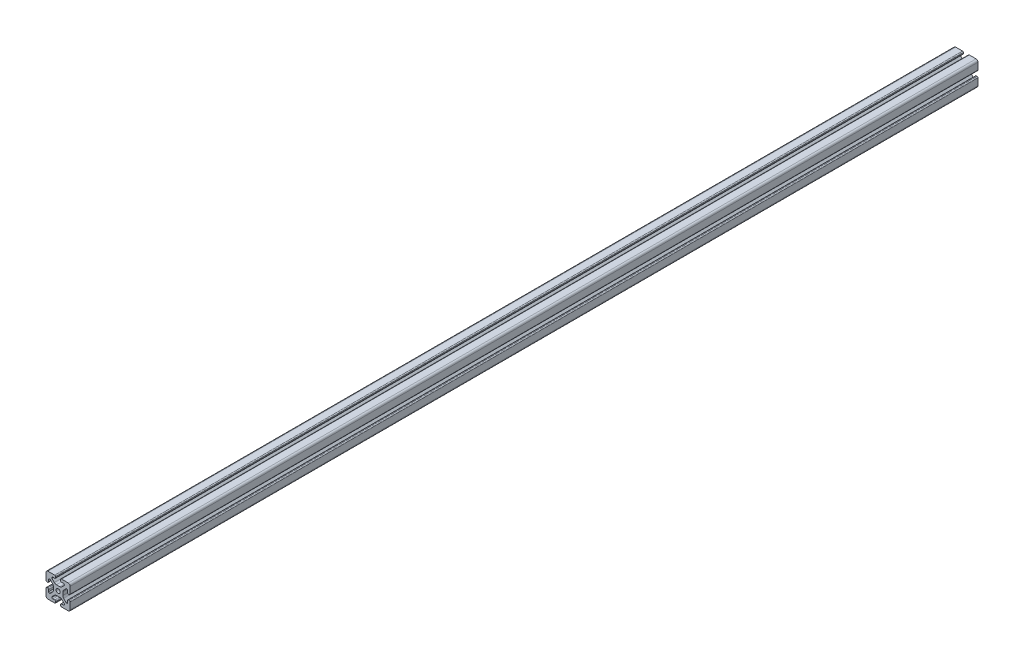
from build123d import *

# Parameters (mm, degrees)
SKETCH1_R           = 3.4
BOSS_EXTRUDE1_DEPTH = 1500


with BuildPart() as part:
    # Sketch1 → Boss-Extrude1 (new body)
    with BuildSketch(Plane.XY):
        with BuildLine():
            Line((-8.715, -15.524615034), (-5.63, -15.524615034))
            ThreePointArc((-5.63, -15.524615034), (-4.519842354, -15.984457388), (-4.06, -17.094615034))
            Line((-4.06, -17.094615034), (-4.06, -18.43))
            ThreePointArc((-4.06, -18.43), (-4.519842354, -19.540157646), (-5.63, -20))
            Line((-5.63, -20), (-16.674615034, -20))
            ThreePointArc((-16.674615034, -20), (-18.951578385, -19.194274381), (-20, -17.018368134))
            Line((-20, -17.018368134), (-20, -5.757918808))
            ThreePointArc((-20, -5.757918808), (-19.564709668, -4.603883664), (-18.43, -4.120449326))
            Line((-18.43, -4.120449326), (-17.248545805, -4.120449326))
            ThreePointArc((-17.248545805, -4.120449326), (-16.114784845, -4.604407881), (-15.67999625, -5.757919334))
            Line((-15.67999625, -5.757919334), (-15.67999625, -8.715399492))
            ThreePointArc((-15.67999625, -8.715399492), (-15.220153896, -9.825557139), (-14.10999625, -10.285399492))
            Line((-14.10999625, -10.285399492), (-13.816903094, -10.285399492))
            ThreePointArc((-13.816903094, -10.285399492), (-13.526063686, -10.227547937), (-13.279501941, -10.062800646))
            Line((-13.279501941, -10.062800646), (-9.076242789, -5.859541495))
            ThreePointArc((-9.076242789, -5.859541495), (-8.046572221, -4.318530588), (-7.685, -2.500784284))
            Line((-7.685, -2.500784284), (-7.685, 2.500784284))
            ThreePointArc((-7.685, 2.500784284), (-8.046572221, 4.318530588), (-9.076242789, 5.859541495))
            Line((-9.076242789, 5.859541495), (-13.040489136, 9.823787841))
            ThreePointArc((-13.040489136, 9.823787841), (-13.354224618, 10.012729352), (-13.71989919, 10.033001362))
            Line((-13.71989919, 10.033001362), (-14.05520779, 10.044710596))
            ThreePointArc((-14.05520779, 10.044710596), (-15.200613642, 9.605030484), (-15.68, 8.475666998))
            Line((-15.68, 8.475666998), (-15.68, 5.572979049))
            ThreePointArc((-15.68, 5.572979049), (-16.139842354, 4.462821403), (-17.25, 4.002979049))
            Line((-17.25, 4.002979049), (-18.43, 4.002979049))
            ThreePointArc((-18.43, 4.002979049), (-19.540157646, 4.462821403), (-20, 5.572979049))
            Line((-20, 5.572979049), (-20, 13.004526564))
            Line((-20, 13.004526564), (-20, 16.83))
            ThreePointArc((-20, 16.83), (-19.071528496, 19.071528496), (-16.83, 20))
            Line((-16.83, 20), (-5.63, 20))
            ThreePointArc((-5.63, 20), (-4.519842354, 19.540157646), (-4.06, 18.43))
            Line((-4.06, 18.43), (-4.06, 17.094615034))
            ThreePointArc((-4.06, 17.094615034), (-4.519842354, 15.984457388), (-5.63, 15.524615034))
            Line((-5.63, 15.524615034), (-8.715, 15.524615034))
            ThreePointArc((-8.715, 15.524615034), (-9.825157646, 15.06477268), (-10.285, 13.954615034))
            Line((-10.285, 13.954615034), (-10.285, 13.492503602))
            ThreePointArc((-10.285, 13.492503602), (-10.227148445, 13.201664194), (-10.062401154, 12.955102448))
            Line((-10.062401154, 12.955102448), (-6.217092793, 9.109794088))
            ThreePointArc((-6.217092793, 9.109794088), (-4.63891877, 8.055291919), (-2.777335583, 7.685))
            Line((-2.777335583, 7.685), (2.777335583, 7.685))
            ThreePointArc((2.777335583, 7.685), (4.63891877, 8.055291919), (6.217092793, 9.109794088))
            Line((6.217092793, 9.109794088), (10.062401154, 12.955102448))
            ThreePointArc((10.062401154, 12.955102448), (10.227148445, 13.201664194), (10.285, 13.492503602))
            Line((10.285, 13.492503602), (10.285, 13.954615034))
            ThreePointArc((10.285, 13.954615034), (9.825157646, 15.06477268), (8.715, 15.524615034))
            Line((8.715, 15.524615034), (5.63, 15.524615034))
            ThreePointArc((5.63, 15.524615034), (4.519842354, 15.984457388), (4.06, 17.094615034))
            Line((4.06, 17.094615034), (4.06, 18.43))
            ThreePointArc((4.06, 18.43), (4.519842354, 19.540157646), (5.63, 20))
            Line((5.63, 20), (12.979635074, 20))
            Line((12.979635074, 20), (16.83, 20))
            ThreePointArc((16.83, 20), (19.071528496, 19.071528496), (20, 16.83))
            Line((20, 16.83), (20, 13.001098436))
            Line((20, 13.001098436), (20, 5.630000526))
            ThreePointArc((20, 5.630000526), (19.540157646, 4.519842879), (18.43, 4.060000526))
            Line((18.43, 4.060000526), (17.24999625, 4.060000526))
            ThreePointArc((17.24999625, 4.060000526), (16.139838603, 4.519842879), (15.67999625, 5.630000526))
            Line((15.67999625, 5.630000526), (15.67999625, 8.715399492))
            ThreePointArc((15.67999625, 8.715399492), (15.220153896, 9.825557139), (14.10999625, 10.285399492))
            Line((14.10999625, 10.285399492), (13.816903094, 10.285399492))
            ThreePointArc((13.816903094, 10.285399492), (13.526063686, 10.227547937), (13.279501941, 10.062800646))
            Line((13.279501941, 10.062800646), (9.076242789, 5.859541495))
            ThreePointArc((9.076242789, 5.859541495), (8.046572221, 4.318530588), (7.685, 2.500784284))
            Line((7.685, 2.500784284), (7.685, -2.500784284))
            ThreePointArc((7.685, -2.500784284), (8.046572221, -4.318530588), (9.076242789, -5.859541495))
            Line((9.076242789, -5.859541495), (13.163657296, -9.946956002))
            ThreePointArc((13.163657296, -9.946956002), (13.35903797, -10.160433474), (13.6200547, -10.285399492))
            Line((13.6200547, -10.285399492), (14.10999625, -10.285399492))
            ThreePointArc((14.10999625, -10.285399492), (15.220153896, -9.825557139), (15.67999625, -8.715399492))
            Line((15.67999625, -8.715399492), (15.67999625, -5.630000526))
            ThreePointArc((15.67999625, -5.630000526), (16.139838603, -4.519842879), (17.24999625, -4.060000526))
            Line((17.24999625, -4.060000526), (18.43, -4.060000526))
            ThreePointArc((18.43, -4.060000526), (19.540157646, -4.519842879), (20, -5.630000526))
            Line((20, -5.630000526), (20, -16.83))
            ThreePointArc((20, -16.83), (19.071528496, -19.071528496), (16.83, -20))
            Line((16.83, -20), (13, -20))
            Line((13, -20), (5.63, -20))
            ThreePointArc((5.63, -20), (4.519842354, -19.540157646), (4.06, -18.43))
            Line((4.06, -18.43), (4.06, -17.094615034))
            ThreePointArc((4.06, -17.094615034), (4.519842354, -15.984457388), (5.63, -15.524615034))
            Line((5.63, -15.524615034), (8.715, -15.524615034))
            ThreePointArc((8.715, -15.524615034), (9.825157646, -15.06477268), (10.285, -13.954615034))
            Line((10.285, -13.954615034), (10.285, -13.492503602))
            ThreePointArc((10.285, -13.492503602), (10.227148445, -13.201664194), (10.062401154, -12.955102448))
            Line((10.062401154, -12.955102448), (6.217092793, -9.109794088))
            ThreePointArc((6.217092793, -9.109794088), (4.63891877, -8.055291919), (2.777335583, -7.685))
            Line((2.777335583, -7.685), (-2.777335583, -7.685))
            ThreePointArc((-2.777335583, -7.685), (-4.63891877, -8.055291919), (-6.217092793, -9.109794088))
            Line((-6.217092793, -9.109794088), (-10.062401154, -12.955102448))
            ThreePointArc((-10.062401154, -12.955102448), (-10.227148445, -13.201664194), (-10.285, -13.492503602))
            Line((-10.285, -13.492503602), (-10.285, -13.954615034))
            ThreePointArc((-10.285, -13.954615034), (-9.825157646, -15.06477268), (-8.715, -15.524615034))
        make_face()
        Circle(SKETCH1_R, mode=Mode.SUBTRACT)
    extrude(amount=BOSS_EXTRUDE1_DEPTH)


solid = part.part
